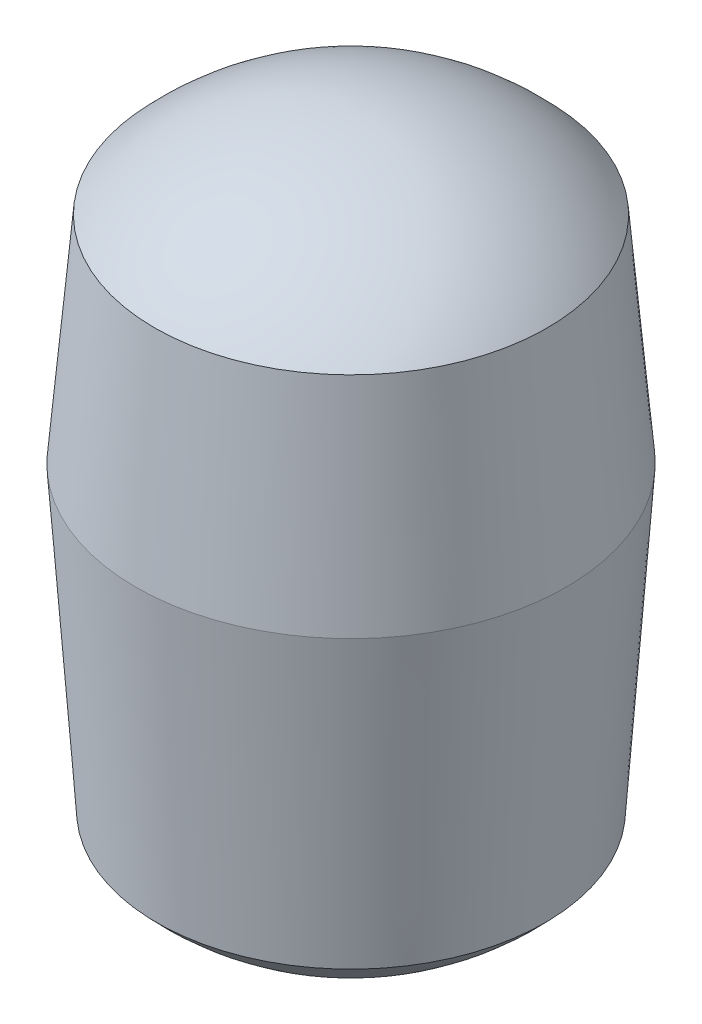
from build123d import *

# Parameters (mm, degrees)
SKETCH1_R           = 0.5
BOSS_EXTRUDE1_DEPTH = 0.5
BOSS_EXTRUDE1_TAPER = 5
DOME1_FACE_RADIUS   = 0.456255668
DOME1_HEIGHT        = 0.2
SKETCH2_R           = 0.5
BOSS_EXTRUDE2_DEPTH = 0.7
BOSS_EXTRUDE2_TAPER = 4
DOME3_FACE_RADIUS   = 0.451051232
DOME3_HEIGHT        = 0.2


with BuildPart() as part:
    # Sketch1 → Boss-Extrude1 (new body)
    with BuildSketch(Plane(origin=(0, 0, 0), x_dir=(1, 0, 0), z_dir=(0, 1, 0))):
        Circle(SKETCH1_R)
    extrude(amount=BOSS_EXTRUDE1_DEPTH, taper=BOSS_EXTRUDE1_TAPER)

    # Dome1: a dome of height H over a round flat face of radius A is a cap of a sphere of radius (A * A + H * H) / (2 * H)
    dome1_r = (DOME1_FACE_RADIUS * DOME1_FACE_RADIUS + DOME1_HEIGHT * DOME1_HEIGHT) / (2 * DOME1_HEIGHT)
    dome1_base = Plane((0, 0.5, 0), z_dir=(0, 1, 0))
    with Locations(dome1_base.offset(DOME1_HEIGHT - dome1_r)):
        dome1_ball = Sphere(dome1_r, mode=Mode.PRIVATE)
    add(split(dome1_ball, bisect_by=dome1_base, keep=Keep.TOP, mode=Mode.PRIVATE))

    # Sketch2 → Boss-Extrude2 (add)
    with BuildSketch(Plane.XZ):
        Circle(SKETCH2_R)
    extrude(amount=BOSS_EXTRUDE2_DEPTH, taper=BOSS_EXTRUDE2_TAPER)

    # Dome3: a dome of height H over a round flat face of radius A is a cap of a sphere of radius (A * A + H * H) / (2 * H)
    dome3_r = (DOME3_FACE_RADIUS * DOME3_FACE_RADIUS + DOME3_HEIGHT * DOME3_HEIGHT) / (2 * DOME3_HEIGHT)
    dome3_base = Plane((0, -0.7, 0), z_dir=(0, -1, 0))
    with Locations(dome3_base.offset(DOME3_HEIGHT - dome3_r)):
        dome3_ball = Sphere(dome3_r, mode=Mode.PRIVATE)
    add(split(dome3_ball, bisect_by=dome3_base, keep=Keep.TOP, mode=Mode.PRIVATE))


solid = part.part
